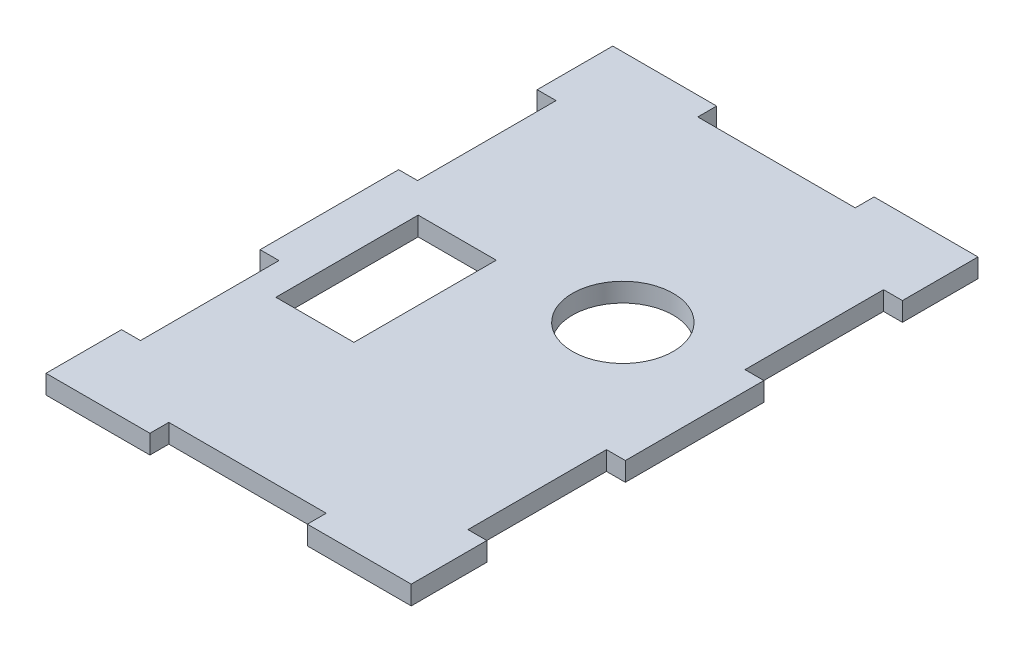
from build123d import *

# Parameters (mm, degrees)
SKETCH4_R           = 8
SKETCH4_W           = 12.4
SKETCH4_H           = 22.6
BOSS_EXTRUDE2_DEPTH = 3


with BuildPart() as part:
    # Sketch4 → Boss-Extrude2 (new body)
    with BuildSketch(Plane(origin=(0, 0, 0), x_dir=(1, 0, 0), z_dir=(0, 1, 0))):
        Polygon((-26, -90), (-9.5, -90), (-9.5, -87), (15.5, -87), (15.5, -90), (32, -90), (32, -78), (29, -78), (29, -56), (32, -56), (32, -34), (29, -34), (29, -12), (32, -12), (32, 0), (15.5, 0), (15.5, -3), (-9.5, -3), (-9.5, 0), (-26, 0), (-26, -12), (-23, -12), (-23, -34), (-26, -34), (-26, -56), (-23, -56), (-23, -78), (-26, -78), align=None)
        with Locations((12.802419237, -37.2)):
            Circle(SKETCH4_R, mode=Mode.SUBTRACT)
        with Locations((-12, -50)):
            Rectangle(SKETCH4_W, SKETCH4_H, mode=Mode.SUBTRACT)
    extrude(amount=BOSS_EXTRUDE2_DEPTH)


solid = part.part
